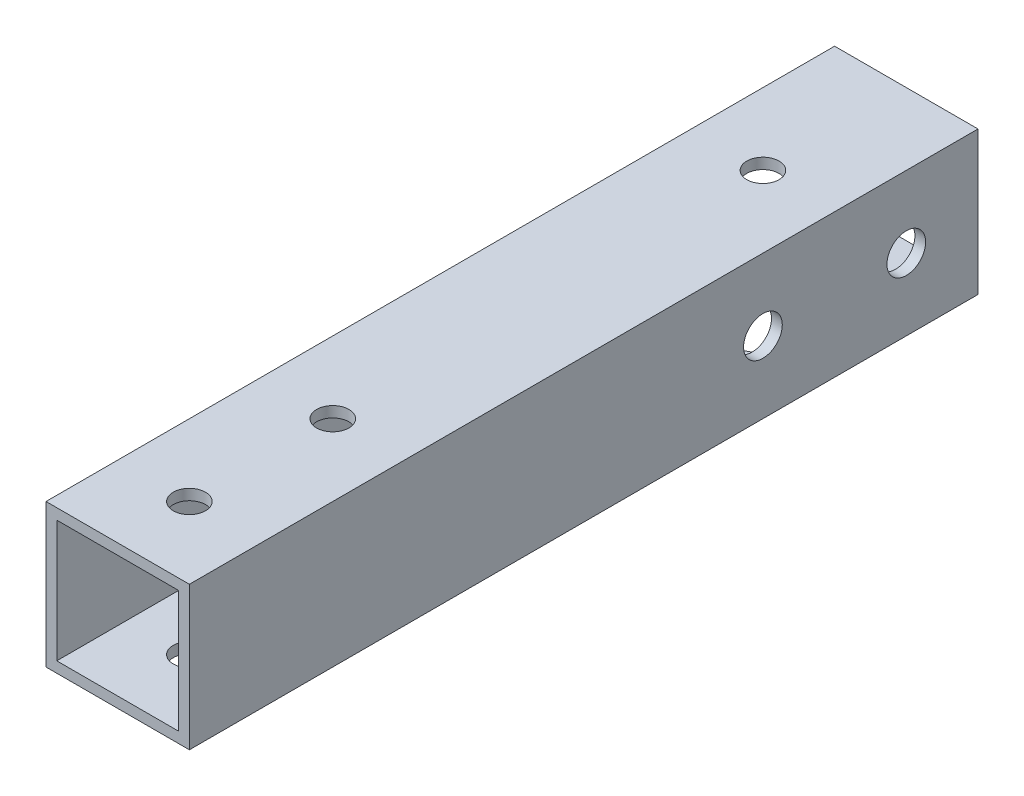
from build123d import *

# Parameters (mm, degrees)
SKETCH_1_W          = 20
SKETCH_1_H          = 20
SKETCH_1_W_2        = 17
SKETCH_1_H_2        = 17
EXTRUDE_1_DEPTH     = 110
SKETCH_2_R          = 2.7
CUT_EXTRUDE_1_DEPTH = 25
SKETCH_3_R          = 2.25
CUT_EXTRUDE_2_DEPTH = 20
SKETCH_4_R          = 2.25
CUT_EXTRUDE_3_DEPTH = 5
SKETCH_5_R          = 5
CUT_EXTRUDE_4_DEPTH = 10
CUT_EXTRUDE_START   = -10
SKETCH_6_R          = 5
CUT_EXTRUDE_5_DEPTH = 10


with BuildPart() as part:
    # ｽｹｯﾁ1 → ﾎﾞｽ - 押し出し1 (new body)
    with BuildSketch(Plane.XY):
        Rectangle(SKETCH_1_W, SKETCH_1_H)
        Rectangle(SKETCH_1_W_2, SKETCH_1_H_2, mode=Mode.SUBTRACT)
    extrude(amount=EXTRUDE_1_DEPTH)

    # ｽｹｯﾁ2 → ｶｯﾄ - 押し出し1 (cut)
    with BuildSketch(Plane(origin=(10, 0, 0), x_dir=(0, 0, -1), z_dir=(1, 0, 0))):
        with Locations((-30, 0)):
            Circle(SKETCH_2_R)
        with Locations((-10, 0)):
            Circle(SKETCH_2_R)
    extrude(amount=-CUT_EXTRUDE_1_DEPTH, mode=Mode.SUBTRACT)

    # ｽｹｯﾁ3 → ｶｯﾄ - 押し出し2 (cut)
    with BuildSketch(Plane(origin=(0, 10, 0), x_dir=(1, 0, 0), z_dir=(0, 1, 0))):
        with Locations((0, -100)):
            Circle(SKETCH_3_R)
        with Locations((0, -80)):
            Circle(SKETCH_3_R)
        with Locations((0, -20)):
            Circle(SKETCH_3_R)
    extrude(amount=-CUT_EXTRUDE_2_DEPTH, mode=Mode.SUBTRACT)

    # ｽｹｯﾁ4 → ｶｯﾄ - 押し出し3 (cut)
    with BuildSketch(Plane(origin=(0, -10, 0), x_dir=(-1, 0, 0), z_dir=(0, -1, 0))):
        with Locations((0, -7.5)):
            Circle(SKETCH_4_R)
    extrude(amount=-CUT_EXTRUDE_3_DEPTH, mode=Mode.SUBTRACT)

    # ｽｹｯﾁ5 → ｶｯﾄ - 押し出し4 (cut)
    with BuildSketch(Plane(origin=(0, -10, 0), x_dir=(-1, 0, 0), z_dir=(0, -1, 0))):
        with Locations((0, -20)):
            Circle(SKETCH_5_R)
    extrude(amount=-CUT_EXTRUDE_4_DEPTH, mode=Mode.SUBTRACT)

    # ｽｹｯﾁ6 → ｶｯﾄ - 押し出し5 (cut)
    with BuildSketch(Plane(origin=(10, 0, 0), x_dir=(0, 0, -1), z_dir=(1, 0, 0)).offset(CUT_EXTRUDE_START)):
        with Locations((-10, 0)):
            Circle(SKETCH_6_R)
        with Locations((-30, 0)):
            Circle(SKETCH_6_R)
    extrude(amount=-CUT_EXTRUDE_5_DEPTH, mode=Mode.SUBTRACT)


solid = part.part
